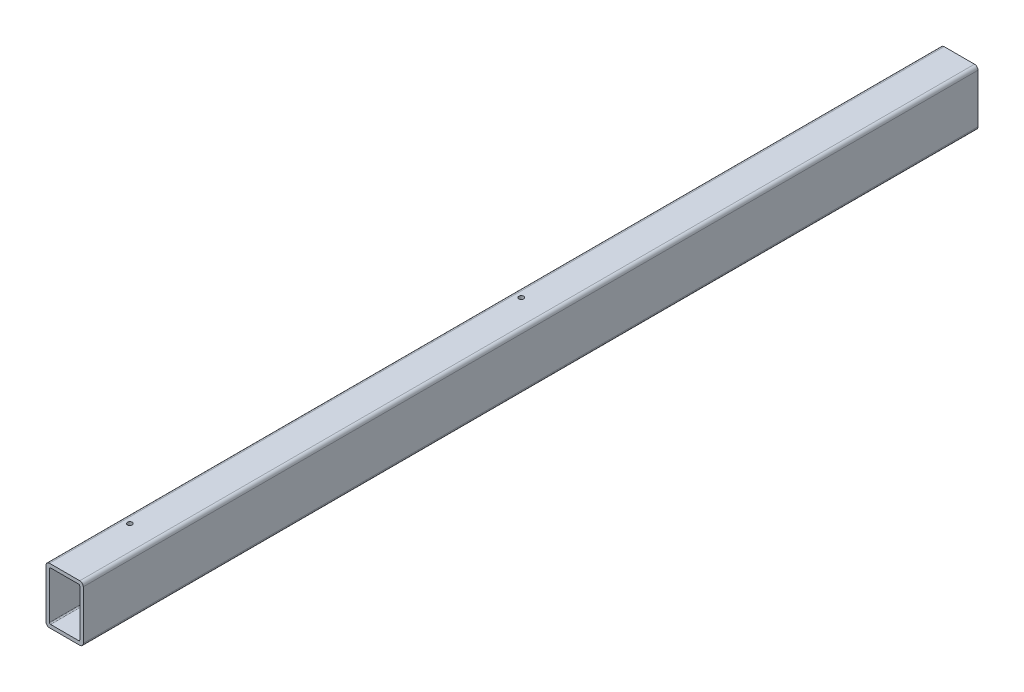
from build123d import *

# Parameters (mm, degrees)
BOSS_EXTRUDE1_DEPTH          = 609.6
F_5_16_18_TAPPED_HOLE1_D     = 6.5278
F_5_16_18_TAPPED_HOLE1_DEPTH = 4.7625


with BuildPart() as part:
    # Sketch1 → Boss-Extrude1 (new body, symmetric)
    with BuildSketch(Plane.XY):
        with BuildLine():
            Line((-20.6375, 38.1), (20.6375, 38.1))
            ThreePointArc((20.6375, 38.1), (24.005096045, 36.705096045), (25.4, 33.3375))
            Line((25.4, 33.3375), (25.4, -33.3375))
            ThreePointArc((25.4, -33.3375), (24.005096045, -36.705096045), (20.6375, -38.1))
            Line((20.6375, -38.1), (-20.6375, -38.1))
            ThreePointArc((-20.6375, -38.1), (-24.005096045, -36.705096045), (-25.4, -33.3375))
            Line((-25.4, -33.3375), (-25.4, 33.3375))
            ThreePointArc((-25.4, 33.3375), (-24.005096045, 36.705096045), (-20.6375, 38.1))
        make_face()
        with BuildLine():
            Line((-19.05, 33.3375), (19.05, 33.3375))
            ThreePointArc((19.05, 33.3375), (20.172532015, 32.872532015), (20.6375, 31.75))
            Line((20.6375, 31.75), (20.6375, -31.75))
            ThreePointArc((20.6375, -31.75), (20.172532015, -32.872532015), (19.05, -33.3375))
            Line((19.05, -33.3375), (-19.05, -33.3375))
            ThreePointArc((-19.05, -33.3375), (-20.172532015, -32.872532015), (-20.6375, -31.75))
            Line((-20.6375, -31.75), (-20.6375, 31.75))
            ThreePointArc((-20.6375, 31.75), (-20.172532015, 32.872532015), (-19.05, 33.3375))
        make_face(mode=Mode.SUBTRACT)
    extrude(amount=BOSS_EXTRUDE1_DEPTH, both=True)

    # 5/16-18 Tapped Hole1
    with Locations(Plane(origin=(0, 38.1, 0), x_dir=(1, 0, 0), z_dir=(0, 1, 0))):
        with Locations((-12.7, -508), (-12.7, 25.4)):
            Hole(F_5_16_18_TAPPED_HOLE1_D / 2, depth=F_5_16_18_TAPPED_HOLE1_DEPTH)


solid = part.part
